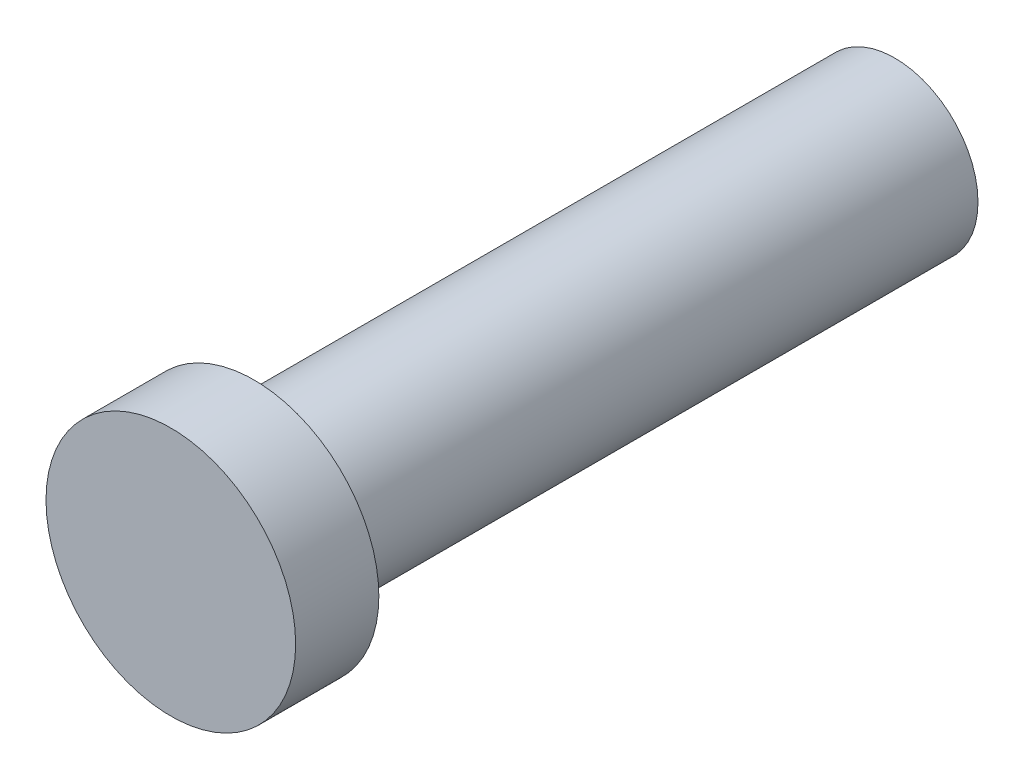
from build123d import *

# Parameters (mm, degrees)
SKETCH1_R           = 1
BOSS_EXTRUDE1_DEPTH = 7.7
SKETCH2_R           = 1.5
BOSS_EXTRUDE2_DEPTH = 1


with BuildPart() as part:
    # Sketch1 → Boss-Extrude1 (new body)
    with BuildSketch(Plane.XY):
        Circle(SKETCH1_R)
    extrude(amount=BOSS_EXTRUDE1_DEPTH)

    # Sketch2 → Boss-Extrude2 (add)
    with BuildSketch(Plane.XY.offset(7.7)):
        Circle(SKETCH2_R)
    extrude(amount=BOSS_EXTRUDE2_DEPTH)


solid = part.part
